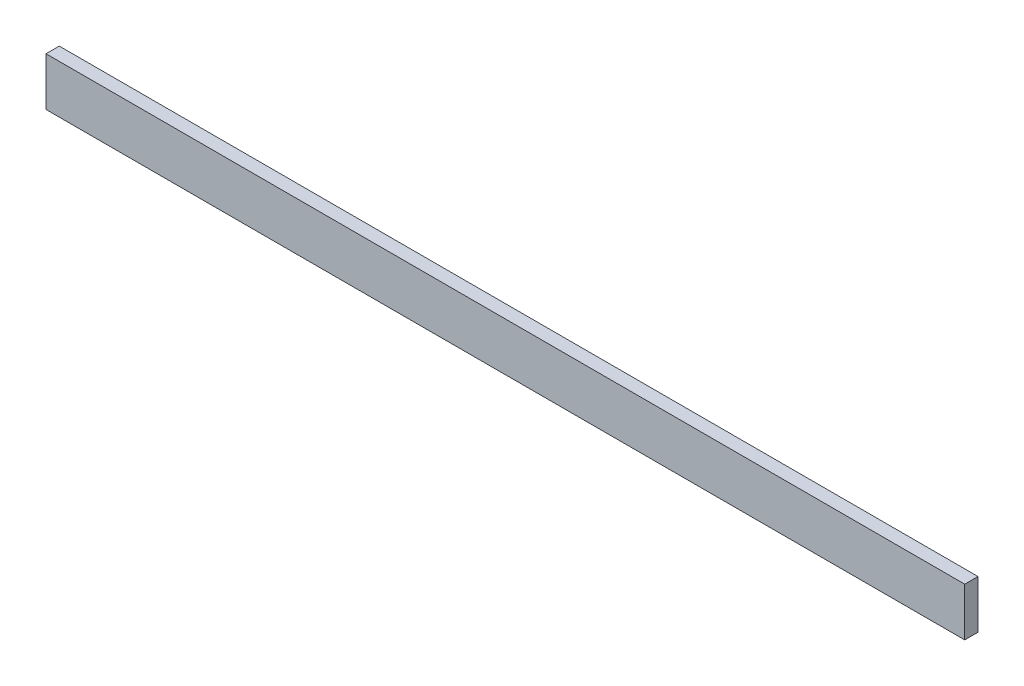
from build123d import *

# Parameters (mm, degrees)
ESQUISSE1_W      = 1522
ESQUISSE1_H      = 80
EXTRUSION1_DEPTH = 22


with BuildPart() as part:
    # Esquisse1 → Extrusion1 (new body)
    with BuildSketch(Plane.XY):
        with Locations((761, 40)):
            Rectangle(ESQUISSE1_W, ESQUISSE1_H)
    extrude(amount=EXTRUSION1_DEPTH)


solid = part.part
